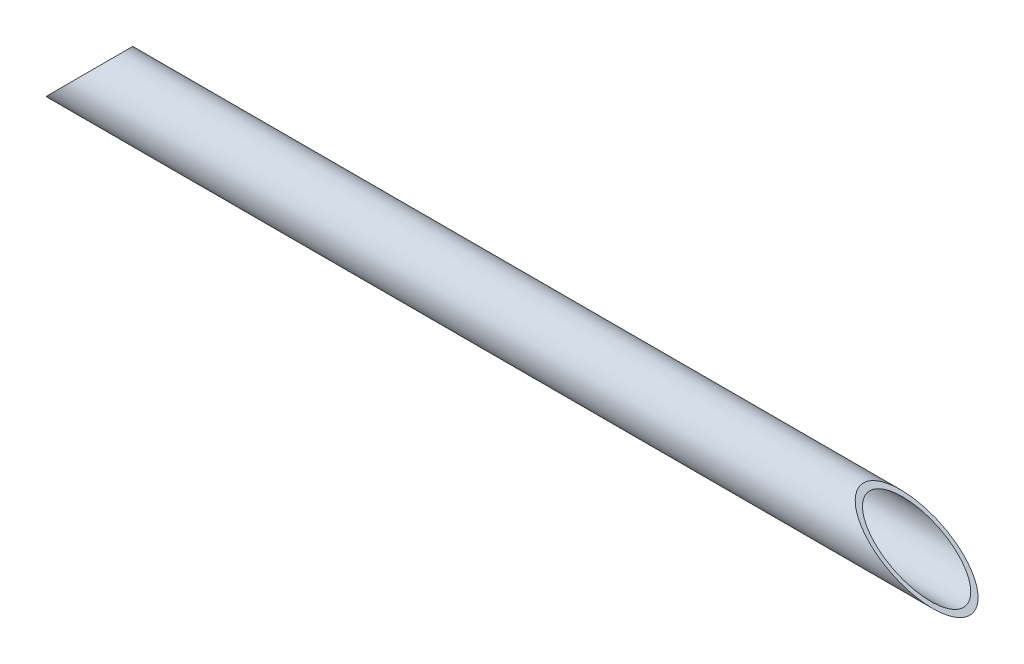
from build123d import *

# Parameters (mm, degrees)
SKETCH1_R               = 16.85
SKETCH1_R_2             = 14.85
ROHR_33_7_X_2_0_1_DEPTH = 500
WINKEL_DEPTH            = 501.567522918
WINKEL_DEPTH_BACK       = 501.567522918


with BuildPart() as part:
    # Sketch1 → Rohr 33.7 X 2.0(1) (new body)
    with BuildSketch(Plane.YZ):
        Circle(SKETCH1_R)
        Circle(SKETCH1_R_2, mode=Mode.SUBTRACT)
    extrude(amount=ROHR_33_7_X_2_0_1_DEPTH)

    # Skizze3 → Winkel (cut, two sides: drawn at the far end of the back side and taken through both)
    with BuildSketch(Plane.XY.offset(-WINKEL_DEPTH_BACK)):
        Polygon((-715.782137289, -732.632137289), (0, -16.85), (122.802873567, 105.952873567), (287.299183666, 105.952873567), (500, -16.85), (1376.650501679, -522.98440313), (1174.815942615, 1491.467223311), (-917.616696354, 1281.819489151), align=None)
    extrude(amount=WINKEL_DEPTH + WINKEL_DEPTH_BACK, mode=Mode.SUBTRACT)


solid = part.part
